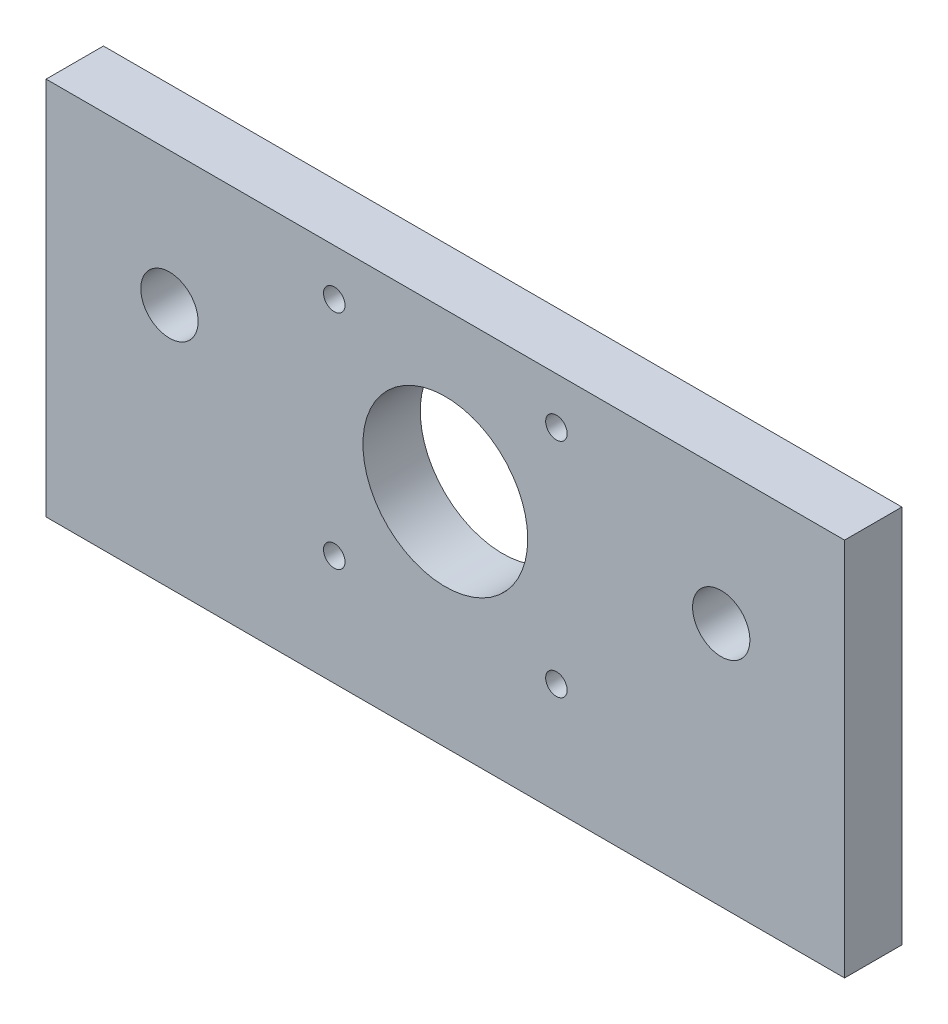
from build123d import *

# Parameters (mm, degrees)
SKETCH1_R           = 4
SKETCH1_R_2         = 5
BOSS_EXTRUDE1_DEPTH = 8
SKETCH2_R           = 11.5
SKETCH2_R_2         = 1.5
CUT_EXTRUDE1_DEPTH  = 9


with BuildPart() as part:
    # Sketch1 → Boss-Extrude1 (new body)
    with BuildSketch(Plane.XY):
        Polygon((-55.929590299, 11.283196531), (55.49624814, 11.283196531), (55.49624814, -41.637870342), (-55.929590299, -41.637870342), (-55.929590299, -36.557898132), align=None)
        with Locations((38.28332892, -7.416803469)):
            Circle(SKETCH1_R, mode=Mode.SUBTRACT)
        with Locations((-0.21667108, -10.716803469)):
            Circle(SKETCH1_R_2, mode=Mode.SUBTRACT)
        with Locations((-38.71667108, -7.416803469)):
            Circle(SKETCH1_R, mode=Mode.SUBTRACT)
    extrude(amount=BOSS_EXTRUDE1_DEPTH)

    # Sketch2 → Cut-Extrude1 (cut, through all)
    with BuildSketch(Plane.XY.offset(8)):
        with Locations((-0.21667108, -10.716803469)):
            Circle(SKETCH2_R)
        with Locations((-15.71667108, -26.216803469)):
            Circle(SKETCH2_R_2)
        with Locations((15.28332892, -26.216803469)):
            Circle(SKETCH2_R_2)
        with Locations((-15.71667108, 4.783196531)):
            Circle(SKETCH2_R_2)
        with Locations((15.28332892, 4.783196531)):
            Circle(SKETCH2_R_2)
    extrude(amount=-CUT_EXTRUDE1_DEPTH, mode=Mode.SUBTRACT)


solid = part.part
